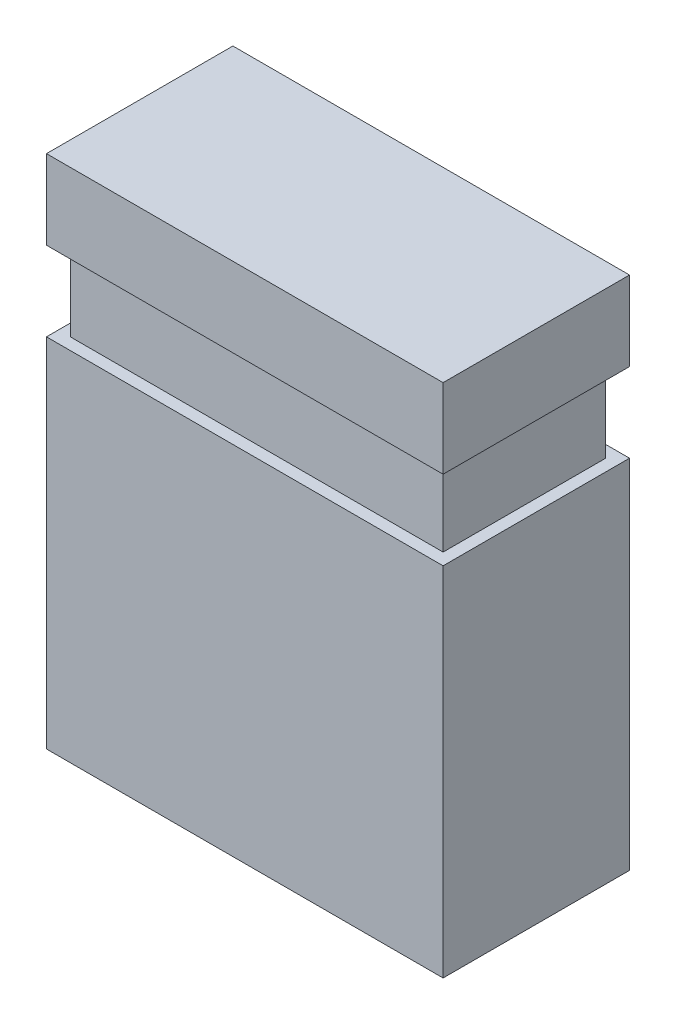
from build123d import *

# Parameters (mm, degrees)
EXTRUDE1_DEPTH      = 1.175
EXTRUDE1_DEPTH_BACK = 1.175
SKETCH1_W           = 5
SKETCH1_H           = 6.5
CUT_EXTRUDE1_START  = -1
SKETCH2_OUTSIDE_W   = 8.706
SKETCH2_OUTSIDE_H   = 6.056
SKETCH2_OUTSIDE_W_2 = 4.7
SKETCH2_OUTSIDE_H_2 = 2.05
CUT_EXTRUDE1_DEPTH  = 1
SKETCH3_W           = 4
SKETCH3_H           = 1.35
CUT_EXTRUDE2_DEPTH  = 4


with BuildPart() as part:
    # Sketch1 → Extrude1 (new, two sides: drawn at the far end of the back side and taken through both)
    with BuildSketch(Plane.XY.offset(-EXTRUDE1_DEPTH_BACK)):
        Rectangle(SKETCH1_W, SKETCH1_H)
    extrude(amount=EXTRUDE1_DEPTH + EXTRUDE1_DEPTH_BACK)

    # Sketch2 outside → Cut-Extrude1 (cut)
    with BuildSketch(Plane(origin=(0, 3.25, 0), x_dir=(1, 0, 0), z_dir=(0, 1, 0)).offset(CUT_EXTRUDE1_START)):
        Rectangle(SKETCH2_OUTSIDE_W, SKETCH2_OUTSIDE_H)
        Rectangle(SKETCH2_OUTSIDE_W_2, SKETCH2_OUTSIDE_H_2, mode=Mode.SUBTRACT)
    extrude(amount=-CUT_EXTRUDE1_DEPTH, mode=Mode.SUBTRACT)

    # Sketch3 → Cut-Extrude2 (cut)
    with BuildSketch(Plane.XZ.offset(3.25)):
        Rectangle(SKETCH3_W, SKETCH3_H)
    extrude(amount=-CUT_EXTRUDE2_DEPTH, mode=Mode.SUBTRACT)


solid = part.part
